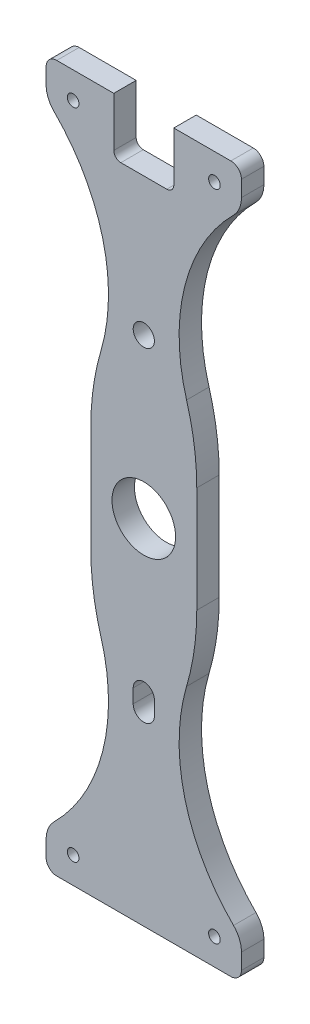
from build123d import *

# Parameters (mm, degrees)
SKETCH1_R           = 9
SKETCH1_R_2         = 3
SKETCH1_R_3         = 1.65
BOSS_EXTRUDE1_DEPTH = 6.35
CUT_EXTRUDE1_DEPTH  = 10


with BuildPart() as part:
    # Sketch1 → Boss-Extrude1 (new body)
    with BuildSketch(Plane.XY):
        with BuildLine():
            Line((-15, 15), (-15, -15))
            ThreePointArc((-15, -15), (-14.275727836, -25.159324804), (-12.117561222, -35.113156605))
            ThreePointArc((-12.117561222, -35.113156605), (-11.640196728, -62.923473964), (-25.409366876, -87.090633124))
            ThreePointArc((-25.409366876, -87.090633124), (-27.067678424, -89.572471742), (-27.65, -92.5))
            Line((-27.65, -92.5), (-27.65, -97))
            ThreePointArc((-27.65, -97), (-26.771320344, -99.121320344), (-24.65, -100))
            Line((-24.65, -100), (24.65, -100))
            ThreePointArc((24.65, -100), (26.771320344, -99.121320344), (27.65, -97))
            Line((27.65, -97), (27.65, -92.5))
            ThreePointArc((27.65, -92.5), (27.067678424, -89.572471742), (25.409366876, -87.090633124))
            ThreePointArc((25.409366876, -87.090633124), (11.640196728, -62.923473964), (12.117561222, -35.113156605))
            ThreePointArc((12.117561222, -35.113156605), (14.275727836, -25.159324804), (15, -15))
            Line((15, -15), (15, 15))
            ThreePointArc((15, 15), (14.275727836, 25.159324804), (12.117561222, 35.113156605))
            ThreePointArc((12.117561222, 35.113156605), (11.640196728, 62.923473964), (25.409366876, 87.090633124))
            ThreePointArc((25.409366876, 87.090633124), (27.067678424, 89.572471742), (27.65, 92.5))
            Line((27.65, 92.5), (27.65, 97))
            ThreePointArc((27.65, 97), (26.771320344, 99.121320344), (24.65, 100))
            Line((24.65, 100), (-24.65, 100))
            ThreePointArc((-24.65, 100), (-26.771320344, 99.121320344), (-27.65, 97))
            Line((-27.65, 97), (-27.65, 92.5))
            ThreePointArc((-27.65, 92.5), (-27.067678424, 89.572471742), (-25.409366876, 87.090633124))
            ThreePointArc((-25.409366876, 87.090633124), (-11.640196728, 62.923473964), (-12.117561222, 35.113156605))
            ThreePointArc((-12.117561222, 35.113156605), (-14.275727836, 25.159324804), (-15, 15))
        make_face()
        Circle(SKETCH1_R, mode=Mode.SUBTRACT)
        with Locations((0, 44.9961)):
            Circle(SKETCH1_R_2, mode=Mode.SUBTRACT)
        with Locations((20, 92.5)):
            Circle(SKETCH1_R_3, mode=Mode.SUBTRACT)
        with Locations((-20, 92.5)):
            Circle(SKETCH1_R_3, mode=Mode.SUBTRACT)
        with Locations((-20, -92.5)):
            Circle(SKETCH1_R_3, mode=Mode.SUBTRACT)
        with Locations((20, -92.5)):
            Circle(SKETCH1_R_3, mode=Mode.SUBTRACT)
        with BuildLine():
            Line((3, -43.0351625), (3, -46.9570375))
            ThreePointArc((3, -46.9570375), (0, -49.9570375), (-3, -46.9570375))
            Line((-3, -46.9570375), (-3, -43.0351625))
            ThreePointArc((-3, -43.0351625), (0, -40.0351625), (3, -43.0351625))
        make_face(mode=Mode.SUBTRACT)
    extrude(amount=BOSS_EXTRUDE1_DEPTH)

    # Sketch3 → Cut-Extrude1 (cut)
    with BuildSketch(Plane.XY.offset(6.35)):
        with BuildLine():
            Line((-8.5, 101), (-8.5, 86))
            ThreePointArc((-8.5, 86), (-7.914213562, 84.585786438), (-6.5, 84))
            Line((-6.5, 84), (6.5, 84))
            ThreePointArc((6.5, 84), (7.914213562, 84.585786438), (8.5, 86))
            Line((8.5, 86), (8.5, 101))
            Line((8.5, 101), (-8.5, 101))
        make_face()
    extrude(amount=-CUT_EXTRUDE1_DEPTH, mode=Mode.SUBTRACT)


solid = part.part
